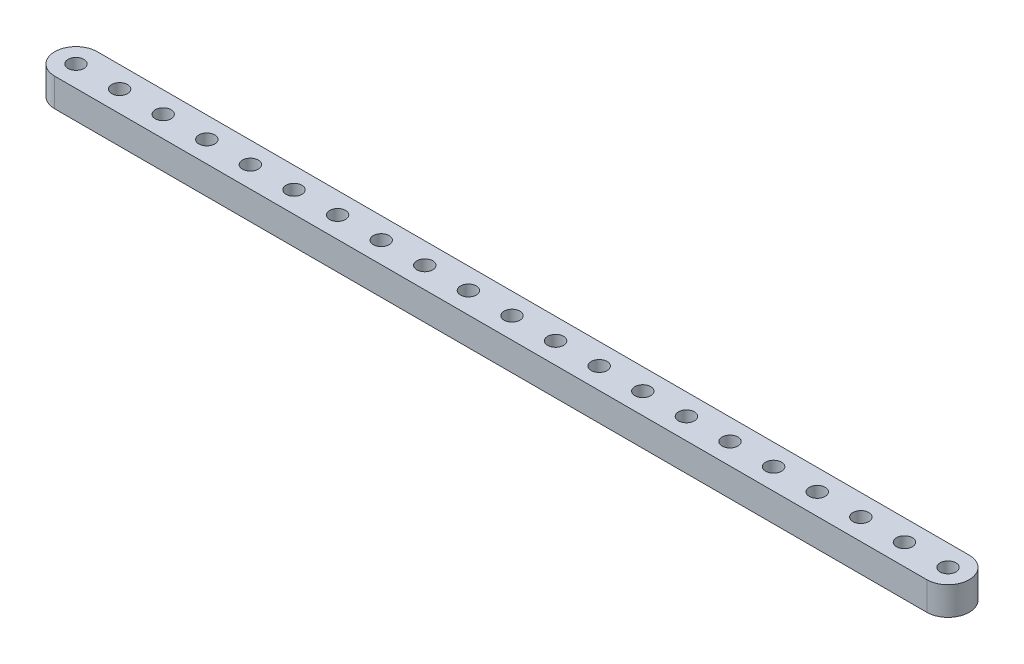
from build123d import *

# Parameters (mm, degrees)
SKETCH1_R           = 1.778
BOSS_EXTRUDE1_DEPTH = 6.35


with BuildPart() as part:
    # Sketch1 → Boss-Extrude1 (new body)
    with BuildSketch(Plane(origin=(0, 6.35, 0), x_dir=(1, 0, 0), z_dir=(0, 1, 0))):
        with BuildLine():
            Line((97.79, 4.7625), (-97.79, 4.7625))
            ThreePointArc((-97.79, 4.7625), (-102.5525, 0), (-97.79, -4.7625))
            Line((-97.79, -4.7625), (97.79, -4.7625))
            ThreePointArc((97.79, -4.7625), (102.5525, 0), (97.79, 4.7625))
        make_face()
        with Locations((97.79, 0)):
            Circle(SKETCH1_R, mode=Mode.SUBTRACT)
        with Locations((88.011, 0)):
            Circle(SKETCH1_R, mode=Mode.SUBTRACT)
        with Locations((78.232, 0)):
            Circle(SKETCH1_R, mode=Mode.SUBTRACT)
        with Locations((68.453, 0)):
            Circle(SKETCH1_R, mode=Mode.SUBTRACT)
        with Locations((58.674, 0)):
            Circle(SKETCH1_R, mode=Mode.SUBTRACT)
        with Locations((48.895, 0)):
            Circle(SKETCH1_R, mode=Mode.SUBTRACT)
        with Locations((39.116, 0)):
            Circle(SKETCH1_R, mode=Mode.SUBTRACT)
        with Locations((29.337, 0)):
            Circle(SKETCH1_R, mode=Mode.SUBTRACT)
        with Locations((19.558, 0)):
            Circle(SKETCH1_R, mode=Mode.SUBTRACT)
        with Locations((9.779, 0)):
            Circle(SKETCH1_R, mode=Mode.SUBTRACT)
        Circle(SKETCH1_R, mode=Mode.SUBTRACT)
        with Locations((-9.779, 0)):
            Circle(SKETCH1_R, mode=Mode.SUBTRACT)
        with Locations((-19.558, 0)):
            Circle(SKETCH1_R, mode=Mode.SUBTRACT)
        with Locations((-29.337, 0)):
            Circle(SKETCH1_R, mode=Mode.SUBTRACT)
        with Locations((-39.116, 0)):
            Circle(SKETCH1_R, mode=Mode.SUBTRACT)
        with Locations((-48.895, 0)):
            Circle(SKETCH1_R, mode=Mode.SUBTRACT)
        with Locations((-58.674, 0)):
            Circle(SKETCH1_R, mode=Mode.SUBTRACT)
        with Locations((-68.453, 0)):
            Circle(SKETCH1_R, mode=Mode.SUBTRACT)
        with Locations((-78.232, 0)):
            Circle(SKETCH1_R, mode=Mode.SUBTRACT)
        with Locations((-88.011, 0)):
            Circle(SKETCH1_R, mode=Mode.SUBTRACT)
        with Locations((-97.79, 0)):
            Circle(SKETCH1_R, mode=Mode.SUBTRACT)
    extrude(amount=-BOSS_EXTRUDE1_DEPTH)


solid = part.part
